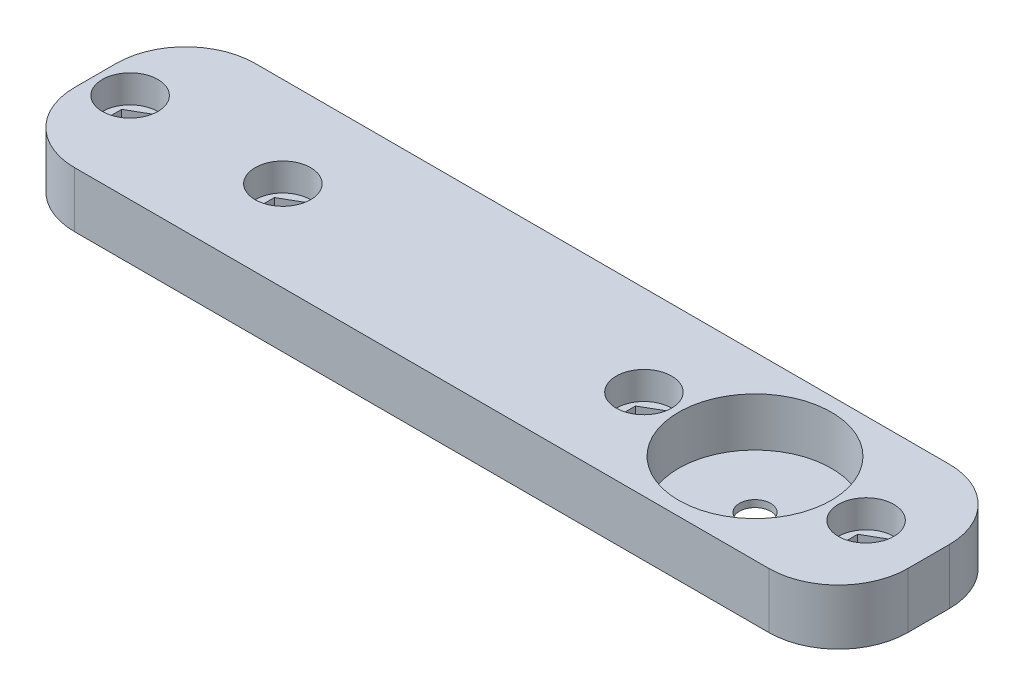
from build123d import *

# Parameters (mm, degrees)
SKETCH1_W                = 120
SKETCH1_H                = 26
BOSS_EXTRUDE1_DEPTH      = 8
SKETCH2_R                = 11
CUT_EXTRUDE1_DEPTH       = 7
SKETCH5_R                = 2.25
CUT_EXTRUDE2_DEPTH       = 2
SKETCH6_R                = 4
CUT_EXTRUDE3_DEPTH       = 4
CUT_EXTRUDE4_DEPTH       = 2.2
M3_CLEARANCE_HOLE1_D     = 3.4
M3_CLEARANCE_HOLE1_DEPTH = 1.8
M4_CLEARANCE_HOLE1_D     = 4.5
SKETCH10_R               = 4
CUT_EXTRUDE5_DEPTH       = 4
CUT_EXTRUDE6_DEPTH       = 2
FILLET1_R                = 10


with BuildPart() as part:
    # Sketch1 → Boss-Extrude1 (new body)
    with BuildSketch(Plane(origin=(0, 0, 0), x_dir=(1, 0, 0), z_dir=(0, 1, 0))):
        Rectangle(SKETCH1_W, SKETCH1_H)
    extrude(amount=BOSS_EXTRUDE1_DEPTH)

    # Sketch2 → Cut-Extrude1 (cut)
    with BuildSketch(Plane(origin=(0, 8, 0), x_dir=(1, 0, 0), z_dir=(0, 1, 0))):
        with Locations((35, 0)):
            Circle(SKETCH2_R)
    extrude(amount=-CUT_EXTRUDE1_DEPTH, mode=Mode.SUBTRACT)

    # Sketch5 → Cut-Extrude2 (cut, through all)
    with BuildSketch(Plane(origin=(0, 1, 0), x_dir=(1, 0, 0), z_dir=(0, 1, 0))):
        with Locations((35, 0)):
            Circle(SKETCH5_R)
    extrude(amount=-CUT_EXTRUDE2_DEPTH, mode=Mode.SUBTRACT)

    # Sketch6 → Cut-Extrude3 (cut)
    with BuildSketch(Plane(origin=(0, 8, 0), x_dir=(1, 0, 0), z_dir=(0, 1, 0))):
        with Locations((51, 0)):
            Circle(SKETCH6_R)
        with Locations((19, 0)):
            Circle(SKETCH6_R)
    extrude(amount=-CUT_EXTRUDE3_DEPTH, mode=Mode.SUBTRACT)

    # Sketch7 → Cut-Extrude4 (cut)
    with BuildSketch(Plane(origin=(0, 4, 0), x_dir=(1, 0, 0), z_dir=(0, 1, 0))):
        Polygon((53.875, -1.659882024), (53.875, 1.659882024), (51, 3.319764048), (48.125, 1.659882024), (48.125, -1.659882024), (51, -3.319764048), align=None)
        Polygon((19, -3.319764048), (16.125, -1.659882024), (16.125, 1.659882024), (19, 3.319764048), (21.875, 1.659882024), (21.875, -1.659882024), align=None)
    extrude(amount=-CUT_EXTRUDE4_DEPTH, mode=Mode.SUBTRACT)

    # M3 Clearance Hole1
    with Locations(Plane(origin=(0, 1.8, 0), x_dir=(1, 0, 0), z_dir=(0, 1, 0))):
        with Locations((51, 0), (19, 0)):
            Hole(M3_CLEARANCE_HOLE1_D / 2, depth=M3_CLEARANCE_HOLE1_DEPTH)

    # M4 Clearance Hole1 (through all)
    with Locations(Plane(origin=(0, 8, 0), x_dir=(1, 0, 0), z_dir=(0, 1, 0))):
        with Locations((-33, 0), (-55, 0)):
            Hole(M4_CLEARANCE_HOLE1_D / 2)

    # Sketch10 → Cut-Extrude5 (cut)
    with BuildSketch(Plane(origin=(0, 8, 0), x_dir=(1, 0, 0), z_dir=(0, 1, 0))):
        with Locations((-55, 0)):
            Circle(SKETCH10_R)
        with Locations((-33, 0)):
            Circle(SKETCH10_R)
    extrude(amount=-CUT_EXTRUDE5_DEPTH, mode=Mode.SUBTRACT)

    # Sketch11 → Cut-Extrude6 (cut)
    with BuildSketch(Plane(origin=(0, 4, 0), x_dir=(1, 0, 0), z_dir=(0, 1, 0))):
        Polygon((-55, -3.319764048), (-52.125, -1.659882024), (-52.125, 1.659882024), (-55, 3.319764048), (-57.875, 1.659882024), (-57.875, -1.659882024), align=None)
        Polygon((-35.875, -1.659882024), (-33, -3.319764048), (-30.125, -1.659882024), (-30.125, 1.659882024), (-33, 3.319764048), (-35.875, 1.659882024), align=None)
    extrude(amount=-CUT_EXTRUDE6_DEPTH, mode=Mode.SUBTRACT)

    # Fillet1
    fillet1_edges = [part.edges().sort_by_distance(p)[0] for p in [
        (-60, 4, -13),
        (60, 4, -13),
        (60, 4, 13),
        (-60, 4, 13),
    ]]
    fillet(fillet1_edges, radius=FILLET1_R)


solid = part.part
